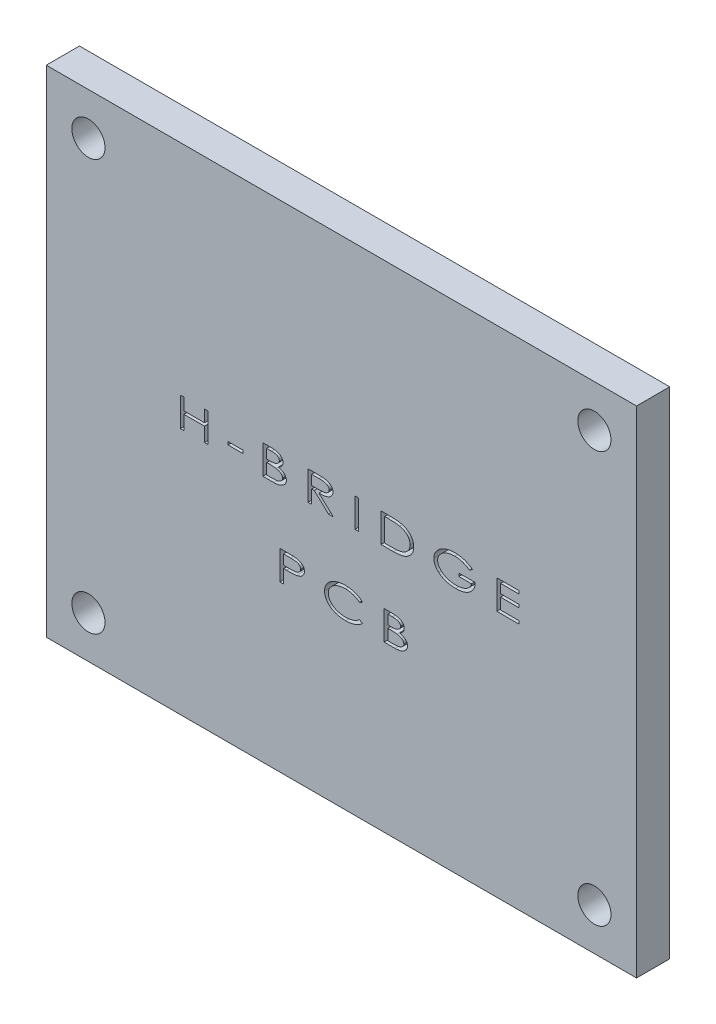
from build123d import *

# Parameters (mm, degrees)
SKETCH1_W           = 71.12
SKETCH1_H           = 59.69
SKETCH1_R           = 2
BOSS_EXTRUDE1_DEPTH = 4
SKETCH2_W           = 1.83974359
SKETCH2_H           = 0.358974359
SKETCH2_W_2         = 0.448717949
SKETCH2_H_2         = 3.5
CUT_EXTRUDE1_DEPTH  = 2


with BuildPart() as part:
    # Sketch1 → Boss-Extrude1 (new body)
    with BuildSketch(Plane.XY):
        Rectangle(SKETCH1_W, SKETCH1_H)
        with Locations((-30.48, 24.765)):
            Circle(SKETCH1_R, mode=Mode.SUBTRACT)
        with Locations((30.48, 24.765)):
            Circle(SKETCH1_R, mode=Mode.SUBTRACT)
        with Locations((30.48, -24.765)):
            Circle(SKETCH1_R, mode=Mode.SUBTRACT)
        with Locations((-30.48, -24.765)):
            Circle(SKETCH1_R, mode=Mode.SUBTRACT)
    extrude(amount=BOSS_EXTRUDE1_DEPTH)

    # Sketch2 → Cut-Extrude1 (cut)
    with BuildSketch(Plane.XY.offset(4)):
        Polygon((-19.416666667, 3.5), (-18.967948718, 3.5), (-18.967948718, 2.064102564), (-16.5, 2.064102564), (-16.5, 3.5), (-16.051282051, 3.5), (-16.051282051, 0), (-16.5, 0), (-16.5, 1.705128205), (-18.967948718, 1.705128205), (-18.967948718, 0), (-19.416666667, 0), align=None)
        with Locations((-12.753205128, 1.346153847)):
            Rectangle(SKETCH2_W, SKETCH2_H)
        with BuildLine():
            Line((-9.455128205, 3.5), (-8.533153045, 3.5))
            add(Edge.make_bspline(
                [(-8.533153045, 3.5), (-8.488041399, 3.499823655), (-8.400593622, 3.499481815), (-8.273430035, 3.494209075), (-8.154368838, 3.487000001), (-8.043325168, 3.475599928), (-7.940396922, 3.46179686), (-7.845331536, 3.445166645), (-7.758375785, 3.425167566), (-7.655029387, 3.393636944), (-7.537589238, 3.346724898), (-7.409410516, 3.277758566), (-7.298608106, 3.192441724), (-7.218657641, 3.111366501), (-7.164194648, 3.041181136), (-7.129110397, 2.986827303), (-7.098696178, 2.931804142), (-7.07450918, 2.87463447), (-7.05599124, 2.816101356), (-7.041358501, 2.756251505), (-7.033885465, 2.694835766), (-7.032665889, 2.653528971), (-7.032051282, 2.63271234)],
                knots=[0, 0, 0, 0, 0.000135324, 0.000262322, 0.000381762, 0.000493105, 0.00059712, 0.000693255, 0.00078254, 0.000864605, 0.001017193, 0.001161224, 0.001299771, 0.001435124, 0.001501598, 0.001565967, 0.001629029, 0.001689975, 0.001751836, 0.001813059, 0.001874543, 0.001937005, 0.001937005, 0.001937005, 0.001937005], degree=3))
            add(Edge.make_bspline(
                [(-7.032051282, 2.63271234), (-7.033801336, 2.593993452), (-7.037259381, 2.517486283), (-7.065054119, 2.405587669), (-7.11041967, 2.299283087), (-7.174112207, 2.199117417), (-7.255788496, 2.10709866), (-7.353442206, 2.022774194), (-7.469103875, 1.948936906), (-7.55435108, 1.908888751), (-7.598557692, 1.888120994)],
                knots=[0, 0, 0, 0, 0.000116044, 0.000229298, 0.000343639, 0.000461511, 0.000583728, 0.000711488, 0.000847429, 0.000993858, 0.000993858, 0.000993858, 0.000993858], degree=3))
            add(Edge.make_bspline(
                [(-7.598557692, 1.888120994), (-7.569061666, 1.880594119), (-7.511692969, 1.865954623), (-7.428851893, 1.841539455), (-7.351819224, 1.815030637), (-7.279017246, 1.789837163), (-7.21232687, 1.761378328), (-7.150027815, 1.733570172), (-7.093206676, 1.704355005), (-7.025702043, 1.663281344), (-6.948905465, 1.609550463), (-6.866194376, 1.538278639), (-6.795490258, 1.459539286), (-6.735294232, 1.375087597), (-6.687437542, 1.285680123), (-6.653271688, 1.191519455), (-6.632366576, 1.093734494), (-6.629596666, 1.02701027), (-6.628205128, 0.993489583)],
                knots=[0, 0, 0, 0, 9.1321e-05, 0.000177616, 0.000258985, 0.000335719, 0.000408636, 0.000476409, 0.00054038, 0.000600141, 0.000713352, 0.00082119, 0.000926929, 0.001030032, 0.001131654, 0.001230131, 0.001329685, 0.001430191, 0.001430191, 0.001430191, 0.001430191], degree=3))
            add(Edge.make_bspline(
                [(-6.628205128, 0.993489583), (-6.629312896, 0.959265668), (-6.631501891, 0.891637791), (-6.652142822, 0.792654516), (-6.684307521, 0.697678316), (-6.730708706, 0.607022938), (-6.790339067, 0.52055519), (-6.862020388, 0.437502288), (-6.947431859, 0.359429113), (-7.044107209, 0.285615537), (-7.152134642, 0.218594814), (-7.269429479, 0.159266074), (-7.396367, 0.110792358), (-7.531669043, 0.069685033), (-7.675943128, 0.038606878), (-7.829152035, 0.016492532), (-7.990902738, 0.001887185), (-8.101930064, 0.000638883), (-8.158754006, 0)],
                knots=[0, 0, 0, 0, 0.000102558, 0.000202659, 0.000301991, 0.000402643, 0.000507072, 0.000616429, 0.000731039, 0.000853599, 0.000980832, 0.001111897, 0.001247306, 0.00138793, 0.001535767, 0.001689556, 0.001852121, 0.002022545, 0.002022545, 0.002022545, 0.002022545], degree=3))
            Line((-8.158754006, 0), (-9.455128205, 0))
            Line((-9.455128205, 0), (-9.455128205, 3.5))
        make_face()
        with BuildLine():
            Line((-9.006410256, 3.141025641), (-9.006410256, 2.019230769))
            Line((-9.006410256, 2.019230769), (-8.730869391, 2.019230769))
            add(Edge.make_bspline(
                [(-8.730869391, 2.019230769), (-8.69043827, 2.019627664), (-8.612371404, 2.020394013), (-8.499197347, 2.022648356), (-8.394514577, 2.028713808), (-8.297882097, 2.035155282), (-8.209720589, 2.04497187), (-8.129819628, 2.057062005), (-8.057966843, 2.069654928), (-7.975191146, 2.0912437), (-7.881777735, 2.122415049), (-7.781559732, 2.171834664), (-7.693219223, 2.230341198), (-7.618240907, 2.298123513), (-7.557164032, 2.37303985), (-7.513254636, 2.45356088), (-7.48523709, 2.538576294), (-7.482266105, 2.596977759), (-7.480769231, 2.626402244)],
                knots=[0, 0, 0, 0, 0.000121302, 0.000234218, 0.000339535, 0.000435845, 0.00052473, 0.000605541, 0.000678286, 0.000743415, 0.000862037, 0.000973036, 0.001077653, 0.001178912, 0.00127516, 0.001366143, 0.001452848, 0.001540891, 0.001540891, 0.001540891, 0.001540891], degree=3))
            add(Edge.make_bspline(
                [(-7.480769231, 2.626402244), (-7.481338977, 2.645864677), (-7.48246102, 2.684193503), (-7.494408609, 2.739692316), (-7.511710492, 2.792544223), (-7.537236579, 2.842004202), (-7.570615094, 2.887808484), (-7.61120844, 2.93012482), (-7.658394963, 2.969491453), (-7.71309168, 3.005620032), (-7.775685219, 3.037576275), (-7.846408359, 3.066036214), (-7.926071023, 3.088290317), (-8.013914704, 3.108464872), (-8.110600888, 3.122197635), (-8.215530749, 3.133928892), (-8.329059106, 3.139833153), (-8.407647214, 3.140618972), (-8.448317308, 3.141025641)],
                knots=[0, 0, 0, 0, 5.8299e-05, 0.000114812, 0.000169576, 0.000224764, 0.000281003, 0.000339027, 0.00040025, 0.000465004, 0.000535245, 0.000610759, 0.000693295, 0.000783107, 0.000880975, 0.000986043, 0.0010998, 0.001221813, 0.001221813, 0.001221813, 0.001221813], degree=3))
            Line((-8.448317308, 3.141025641), (-9.006410256, 3.141025641))
        make_face(mode=Mode.SUBTRACT)
        with BuildLine():
            Line((-9.006410256, 1.66025641), (-9.006410256, 0.358974359))
            Line((-9.006410256, 0.358974359), (-8.404847756, 0.358974359))
            add(Edge.make_bspline(
                [(-8.404847756, 0.358974359), (-8.362078425, 0.359357953), (-8.279335763, 0.360100063), (-8.159636132, 0.362535474), (-8.048787346, 0.367915566), (-7.947163216, 0.376730185), (-7.854214245, 0.385933314), (-7.770267569, 0.39860839), (-7.694891342, 0.413161535), (-7.607533136, 0.43499843), (-7.509358061, 0.469539183), (-7.402801018, 0.521269749), (-7.3081888, 0.583415811), (-7.227191442, 0.655182766), (-7.160951009, 0.733564611), (-7.11291371, 0.817027218), (-7.081883396, 0.903937782), (-7.078567704, 0.963798082), (-7.076923077, 0.993489583)],
                knots=[0, 0, 0, 0, 0.000128313, 0.000248238, 0.000359157, 0.000461167, 0.000554234, 0.00063931, 0.000715761, 0.00078446, 0.000909301, 0.0010272, 0.001139013, 0.001247778, 0.001350833, 0.001445362, 0.0015356, 0.001624411, 0.001624411, 0.001624411, 0.001624411], degree=3))
            add(Edge.make_bspline(
                [(-7.076923077, 0.993489583), (-7.077659306, 1.01198932), (-7.079123434, 1.048779465), (-7.088975002, 1.103097196), (-7.106319827, 1.15538333), (-7.129094607, 1.20616788), (-7.160298225, 1.25439578), (-7.197281808, 1.301223856), (-7.241095924, 1.346179895), (-7.291144554, 1.389013457), (-7.34683226, 1.429141457), (-7.407545478, 1.466811295), (-7.473759477, 1.500057931), (-7.544547024, 1.531077333), (-7.620674635, 1.558454685), (-7.701763653, 1.581976813), (-7.787896942, 1.602476333), (-7.847166602, 1.613321009), (-7.877604167, 1.618890224)],
                knots=[0, 0, 0, 0, 5.5499e-05, 0.000110371, 0.000164914, 0.000220445, 0.000276854, 0.000336749, 0.000399224, 0.000464853, 0.000534133, 0.00060496, 0.000678961, 0.000756202, 0.000836709, 0.00092146, 0.001009381, 0.001102197, 0.001102197, 0.001102197, 0.001102197], degree=3))
            add(Edge.make_bspline(
                [(-7.877604167, 1.618890224), (-7.900016437, 1.622341709), (-7.948450755, 1.629800583), (-8.027079168, 1.637770294), (-8.117077628, 1.644824844), (-8.218560148, 1.649973796), (-8.331416353, 1.655379203), (-8.455559113, 1.657486227), (-8.591102698, 1.659986103), (-8.685294826, 1.660163812), (-8.734375, 1.66025641)],
                knots=[0, 0, 0, 0, 6.802e-05, 0.000146995, 0.000237012, 0.000338829, 0.000451816, 0.000575947, 0.000711279, 0.000858517, 0.000858517, 0.000858517, 0.000858517], degree=3))
            Line((-8.734375, 1.66025641), (-9.006410256, 1.66025641))
        make_face(mode=Mode.SUBTRACT)
        with BuildLine():
            Line((-4.025641026, 3.5), (-3.067908654, 3.5))
            add(Edge.make_bspline(
                [(-3.067908654, 3.5), (-3.003873069, 3.499846464), (-2.88117335, 3.49955227), (-2.705167203, 3.497863617), (-2.545330065, 3.493121233), (-2.401538212, 3.488992081), (-2.274195206, 3.481521981), (-2.16285684, 3.474375001), (-2.067645333, 3.464910648), (-2.009656411, 3.456259654), (-1.983273237, 3.452323718)],
                knots=[0, 0, 0, 0, 0.000192109, 0.000368103, 0.000528014, 0.000671828, 0.000799624, 0.00091067, 0.001006526, 0.001086543, 0.001086543, 0.001086543, 0.001086543], degree=3))
            add(Edge.make_bspline(
                [(-1.983273237, 3.452323718), (-1.948350403, 3.446016522), (-1.879667628, 3.433612154), (-1.780038146, 3.407255004), (-1.685197473, 3.376468726), (-1.59516043, 3.341085056), (-1.510683828, 3.299117541), (-1.430747547, 3.253219852), (-1.355803971, 3.201790331), (-1.287093895, 3.145035008), (-1.223313109, 3.085594585), (-1.169562267, 3.020342373), (-1.122637687, 2.952943451), (-1.084323259, 2.881814355), (-1.055877801, 2.806887279), (-1.03439104, 2.729044074), (-1.021615894, 2.647624197), (-1.020031949, 2.592091546), (-1.019230769, 2.564002404)],
                knots=[0, 0, 0, 0, 0.000106427, 0.000209311, 0.000308863, 0.000405468, 0.000499222, 0.000591578, 0.000681816, 0.000771499, 0.000858777, 0.000942891, 0.001024571, 0.00110487, 0.001184555, 0.001264495, 0.001346799, 0.001431038, 0.001431038, 0.001431038, 0.001431038], degree=3))
            add(Edge.make_bspline(
                [(-1.019230769, 2.564002404), (-1.019690919, 2.540365148), (-1.020601109, 2.493609942), (-1.030237201, 2.424675525), (-1.044738154, 2.358008324), (-1.065307927, 2.293422705), (-1.091847811, 2.231209558), (-1.124685877, 2.171186918), (-1.162233527, 2.112784203), (-1.20670647, 2.057406857), (-1.256669546, 2.005187097), (-1.310635779, 1.954783687), (-1.370525735, 1.908784212), (-1.435260917, 1.865613982), (-1.505563392, 1.826945281), (-1.580108615, 1.789908276), (-1.660135093, 1.757308465), (-1.745486672, 1.727570456), (-1.837775901, 1.701628298), (-1.93758234, 1.678380703), (-2.046088467, 1.660026734), (-2.162482968, 1.643701792), (-2.287158214, 1.631343142), (-2.42019787, 1.622293204), (-2.561417226, 1.616674367), (-2.658448283, 1.615821967), (-2.708233173, 1.615384615)],
                knots=[0, 0, 0, 0, 7.0869e-05, 0.000140181, 0.000208395, 0.000275359, 0.000343208, 0.000410971, 0.000480396, 0.000551241, 0.00062365, 0.000697084, 0.000772535, 0.000849929, 0.000930286, 0.001013066, 0.00109952, 0.001189322, 0.001284087, 0.001386983, 0.001496602, 0.0016141, 0.001739536, 0.001872362, 0.002014099, 0.002163453, 0.002163453, 0.002163453, 0.002163453], degree=3))
            Line((-2.708233173, 1.615384615), (-0.974358974, 0))
            Line((-0.974358974, 0), (-1.543669872, 0))
            Line((-1.543669872, 0), (-3.277544071, 1.615384615))
            Line((-3.277544071, 1.615384615), (-3.576923077, 1.615384615))
            Line((-3.576923077, 1.615384615), (-3.576923077, 0))
            Line((-3.576923077, 0), (-4.025641026, 0))
            Line((-4.025641026, 0), (-4.025641026, 3.5))
        make_face()
        with BuildLine():
            Line((-3.576923077, 3.141025641), (-3.576923077, 1.974358974))
            Line((-3.576923077, 1.974358974), (-2.716646635, 1.969451122))
            add(Edge.make_bspline(
                [(-2.716646635, 1.969451122), (-2.676211126, 1.969434552), (-2.598127372, 1.969402554), (-2.485247007, 1.973406262), (-2.380499969, 1.97794307), (-2.283932675, 1.984879775), (-2.195301774, 1.993908084), (-2.114820101, 2.004943879), (-2.042469676, 2.018044391), (-1.958558809, 2.038249345), (-1.864887366, 2.069306504), (-1.763530494, 2.116181243), (-1.67596091, 2.173985543), (-1.601615238, 2.240628404), (-1.542652297, 2.314695009), (-1.499249389, 2.3939186), (-1.472777791, 2.477970848), (-1.469559341, 2.535775888), (-1.467948718, 2.564703526)],
                knots=[0, 0, 0, 0, 0.000121296, 0.000234231, 0.000338813, 0.000435822, 0.000524632, 0.000606038, 0.000679472, 0.000745112, 0.000864838, 0.000974923, 0.001079152, 0.001178429, 0.001273255, 0.001361721, 0.001448218, 0.001534866, 0.001534866, 0.001534866, 0.001534866], degree=3))
            add(Edge.make_bspline(
                [(-1.467948718, 2.564703526), (-1.469561864, 2.592934747), (-1.47278688, 2.649374857), (-1.499368018, 2.731662988), (-1.543249257, 2.809140843), (-1.603532945, 2.880965136), (-1.676465592, 2.94617385), (-1.761414973, 3.002487793), (-1.857179356, 3.047607995), (-1.945241266, 3.07695664), (-2.024070736, 3.095210486), (-2.093086399, 3.107643545), (-2.17122866, 3.118073547), (-2.25849566, 3.126154967), (-2.35478717, 3.133260414), (-2.460462533, 3.13800775), (-2.575004133, 3.140813302), (-2.654478756, 3.140953222), (-2.695612981, 3.141025641)],
                knots=[0, 0, 0, 0, 8.4554e-05, 0.000169042, 0.000256617, 0.000350248, 0.000449056, 0.000549201, 0.000654885, 0.000765742, 0.000826965, 0.000897514, 0.000976046, 0.001063391, 0.0011604, 0.001265682, 0.0013807, 0.0015041, 0.0015041, 0.0015041, 0.0015041], degree=3))
            Line((-2.695612981, 3.141025641), (-3.576923077, 3.141025641))
        make_face(mode=Mode.SUBTRACT)
        with Locations((1.852564103, 1.75)):
            Rectangle(SKETCH2_W_2, SKETCH2_H_2)
        with BuildLine():
            Line((4.769230769, 0), (4.769230769, 3.5))
            Line((4.769230769, 3.5), (5.740985577, 3.5))
            add(Edge.make_bspline(
                [(5.740985577, 3.5), (5.82559047, 3.499556846), (5.988976861, 3.498701041), (6.224840058, 3.49329804), (6.442958631, 3.483683773), (6.6428254, 3.469712491), (6.82503906, 3.452621883), (6.989008867, 3.43109482), (7.135147401, 3.40592615), (7.225589237, 3.384059125), (7.268028846, 3.373798077)],
                knots=[0, 0, 0, 0, 0.000253815, 0.000490159, 0.000707729, 0.000908739, 0.001091174, 0.00125667, 0.001404792, 0.00153575, 0.00153575, 0.00153575, 0.00153575], degree=3))
            add(Edge.make_bspline(
                [(7.268028846, 3.373798077), (7.323650764, 3.358428176), (7.432734778, 3.328285194), (7.589603002, 3.270981315), (7.737033767, 3.205640317), (7.875989649, 3.133234847), (8.004137, 3.050433379), (8.124525342, 2.961519036), (8.234446261, 2.863076274), (8.335036608, 2.757242699), (8.424428735, 2.644324801), (8.503828648, 2.526490871), (8.56966984, 2.402427242), (8.624138475, 2.273450208), (8.666229983, 2.138894546), (8.696442033, 1.99907483), (8.71405923, 1.853982615), (8.716640607, 1.755656158), (8.717948718, 1.705829327)],
                knots=[0, 0, 0, 0, 0.000173065, 0.00033941, 0.000500437, 0.000656624, 0.000808911, 0.000957689, 0.001105174, 0.001250983, 0.001395191, 0.001536755, 0.00167665, 0.00181585, 0.001956217, 0.00209896, 0.002244451, 0.002393923, 0.002393923, 0.002393923, 0.002393923], degree=3))
            add(Edge.make_bspline(
                [(8.717948718, 1.705829327), (8.716961583, 1.662559049), (8.715014074, 1.577191455), (8.70089318, 1.451211921), (8.676694714, 1.329432547), (8.64434261, 1.211077254), (8.599915847, 1.097425633), (8.548439005, 0.986760526), (8.486356388, 0.880537952), (8.414679633, 0.779250537), (8.335917172, 0.683192567), (8.2511237, 0.592798516), (8.161200295, 0.508542914), (8.064165297, 0.432156117), (7.962755073, 0.360978349), (7.854824649, 0.297005057), (7.741261843, 0.2398555), (7.621472064, 0.187739326), (7.492646551, 0.142652001), (7.352539142, 0.104209634), (7.200238921, 0.072463419), (7.035761135, 0.045957686), (6.859173344, 0.024954578), (6.670390748, 0.010790902), (6.46954928, 0.001267706), (6.331575711, 0.000430946), (6.260516827, 0)],
                knots=[0, 0, 0, 0, 0.0001298, 0.000256082, 0.000379696, 0.000502008, 0.000623623, 0.000745314, 0.00086785, 0.000992146, 0.0011172, 0.001240214, 0.001363741, 0.001486487, 0.001610382, 0.001735193, 0.001862497, 0.001991568, 0.002126832, 0.002271586, 0.00242711, 0.002593322, 0.002771252, 0.002960428, 0.003161155, 0.003374315, 0.003374315, 0.003374315, 0.003374315], degree=3))
            Line((6.260516827, 0), (4.769230769, 0))
        make_face()
        with BuildLine():
            Line((5.217948718, 0.358974359), (5.764823718, 0.358974359))
            add(Edge.make_bspline(
                [(5.764823718, 0.358974359), (5.843351352, 0.359220203), (5.994108698, 0.359692173), (6.211015271, 0.363896695), (6.409232287, 0.370736596), (6.588779924, 0.380259921), (6.749358373, 0.392971345), (6.89116478, 0.407058556), (7.014330452, 0.424697068), (7.089543055, 0.440646553), (7.124298878, 0.448016827)],
                knots=[0, 0, 0, 0, 0.000235581, 0.000452269, 0.00065081, 0.000830565, 0.000991617, 0.001134007, 0.00125805, 0.001364614, 0.001364614, 0.001364614, 0.001364614], degree=3))
            add(Edge.make_bspline(
                [(7.124298878, 0.448016827), (7.167659857, 0.459250295), (7.252950205, 0.481346345), (7.376480427, 0.521632052), (7.49218215, 0.569602837), (7.601147639, 0.62296896), (7.702780592, 0.68306515), (7.796924552, 0.750096987), (7.884647313, 0.822425504), (7.964411351, 0.901531189), (8.035859461, 0.986320247), (8.098651975, 1.075493697), (8.151750631, 1.169332902), (8.194505849, 1.268168418), (8.228350318, 1.371387669), (8.25208843, 1.479184457), (8.266363951, 1.591395565), (8.268263727, 1.667692859), (8.269230769, 1.706530449)],
                knots=[0, 0, 0, 0, 0.000134361, 0.000264287, 0.000389411, 0.000509816, 0.000628015, 0.00074318, 0.0008562, 0.000968741, 0.001079698, 0.001188428, 0.001295482, 0.001402552, 0.001510972, 0.00162086, 0.001733217, 0.001849707, 0.001849707, 0.001849707, 0.001849707], degree=3))
            add(Edge.make_bspline(
                [(8.269230769, 1.706530449), (8.268448596, 1.747488208), (8.266909138, 1.828100476), (8.249955019, 1.946331201), (8.224049923, 2.059878504), (8.188472741, 2.169386991), (8.141069454, 2.273863339), (8.083943853, 2.374187068), (8.016410201, 2.469829048), (7.938345896, 2.56009143), (7.851537607, 2.644731211), (7.756456879, 2.7230537), (7.652701412, 2.793823435), (7.541383069, 2.858535888), (7.42123305, 2.915130861), (7.293780268, 2.965774315), (7.157729291, 3.008566805), (7.063680965, 3.03126862), (7.015625, 3.04286859)],
                knots=[0, 0, 0, 0, 0.000122794, 0.000241682, 0.000357505, 0.00047191, 0.000586453, 0.000701071, 0.000817786, 0.000937104, 0.001058577, 0.001181115, 0.001306162, 0.001434957, 0.001566986, 0.001704212, 0.001846127, 0.001994409, 0.001994409, 0.001994409, 0.001994409], degree=3))
            add(Edge.make_bspline(
                [(7.015625, 3.04286859), (6.975734942, 3.051006147), (6.890268729, 3.068441223), (6.752030967, 3.08694971), (6.596103905, 3.103779657), (6.422166464, 3.117723776), (6.230211653, 3.127809096), (6.020313996, 3.135394023), (5.792426227, 3.14049617), (5.634418027, 3.140844695), (5.552383814, 3.141025641)],
                knots=[0, 0, 0, 0, 0.000122104, 0.000261613, 0.000418169, 0.000592612, 0.000785007, 0.000994784, 0.001222701, 0.001468799, 0.001468799, 0.001468799, 0.001468799], degree=3))
            Line((5.552383814, 3.141025641), (5.217948718, 3.141025641))
            Line((5.217948718, 3.141025641), (5.217948718, 0.358974359))
        make_face(mode=Mode.SUBTRACT)
        with BuildLine():
            Line((15.807692308, 2.902644231), (15.438201122, 2.647435897))
            add(Edge.make_bspline(
                [(15.438201122, 2.647435897), (15.372307745, 2.693412707), (15.240817678, 2.785159316), (15.030817679, 2.902970077), (14.811255352, 3.0026264), (14.584552522, 3.084506932), (14.355208529, 3.149771584), (14.126870444, 3.1957973), (13.901431154, 3.225605673), (13.751859478, 3.22905744), (13.677684295, 3.230769231)],
                knots=[0, 0, 0, 0, 0.000240934, 0.000480783, 0.000721124, 0.000963543, 0.001203251, 0.001435766, 0.001661871, 0.001884314, 0.001884314, 0.001884314, 0.001884314], degree=3))
            add(Edge.make_bspline(
                [(13.677684295, 3.230769231), (13.632090072, 3.230370905), (13.541493358, 3.229579422), (13.406561006, 3.218906279), (13.273373019, 3.203974248), (13.141678069, 3.181936798), (13.011532743, 3.15410732), (12.882884311, 3.119539442), (12.755991596, 3.079027706), (12.631922615, 3.032029985), (12.511747769, 2.980899222), (12.398163735, 2.923881052), (12.291111498, 2.863050848), (12.191464964, 2.797030944), (12.098670414, 2.726587495), (12.011973544, 2.652655217), (11.933438256, 2.572973129), (11.861970237, 2.489799576), (11.798552069, 2.403833455), (11.742391499, 2.316557405), (11.695668024, 2.22748331), (11.656557363, 2.13768355), (11.627129943, 2.046213608), (11.605123623, 1.9539458), (11.592189052, 1.859976263), (11.590560599, 1.797013619), (11.58974359, 1.765424679)],
                knots=[0, 0, 0, 0, 0.000136748, 0.00027172, 0.000405823, 0.000538723, 0.000672113, 0.000804938, 0.000938197, 0.001071545, 0.001202825, 0.001329813, 0.001452606, 0.001572003, 0.00168811, 0.001801953, 0.001913502, 0.00202339, 0.002130664, 0.002233748, 0.002334422, 0.0024321, 0.002527217, 0.002622283, 0.002716383, 0.002811128, 0.002811128, 0.002811128, 0.002811128], degree=3))
            add(Edge.make_bspline(
                [(11.58974359, 1.765424679), (11.590422821, 1.733115092), (11.591782866, 1.668420651), (11.606883835, 1.572321134), (11.628723505, 1.476999581), (11.661867147, 1.383517032), (11.702367156, 1.290687303), (11.752397439, 1.199066789), (11.812505704, 1.109591483), (11.880270554, 1.021183884), (11.956403599, 0.936317022), (12.039633244, 0.855094779), (12.129805163, 0.778888305), (12.227650969, 0.707817213), (12.331493636, 0.640525859), (12.443087446, 0.578931918), (12.560885037, 0.521272196), (12.685256966, 0.469043269), (12.814776057, 0.42239357), (12.947704026, 0.380738679), (13.08402783, 0.346551112), (13.223296958, 0.318683384), (13.365419242, 0.295778234), (13.510819568, 0.281084179), (13.659061462, 0.270385467), (13.75899428, 0.269618404), (13.809495192, 0.269230769)],
                knots=[0, 0, 0, 0, 9.6846e-05, 0.000193918, 0.000291192, 0.000389861, 0.000490949, 0.000594803, 0.000702532, 0.000814019, 0.000928723, 0.001044246, 0.001162655, 0.001282555, 0.001406828, 0.001533628, 0.001664698, 0.001800124, 0.001938076, 0.002077564, 0.002217853, 0.002359479, 0.002503565, 0.002649514, 0.002797776, 0.002949244, 0.002949244, 0.002949244, 0.002949244], degree=3))
            add(Edge.make_bspline(
                [(13.809495192, 0.269230769), (13.870288202, 0.270178016), (13.989468558, 0.272035026), (14.164546832, 0.286468638), (14.332521673, 0.309114976), (14.493371956, 0.342218275), (14.647271174, 0.384258952), (14.794229939, 0.435099334), (14.933483113, 0.496535034), (15.06484799, 0.56616819), (15.18623061, 0.643316664), (15.295661728, 0.726742222), (15.391373105, 0.816293072), (15.475281125, 0.910424118), (15.544880788, 1.011150366), (15.601527817, 1.117457581), (15.645856092, 1.22910387), (15.663988855, 1.30707502), (15.673076923, 1.346153846)],
                knots=[0, 0, 0, 0, 0.000182358, 0.000357499, 0.000526657, 0.000690561, 0.000849765, 0.001004981, 0.001156613, 0.00130591, 0.001450615, 0.001587623, 0.001718086, 0.001843272, 0.001965214, 0.002084405, 0.002204059, 0.002324286, 0.002324286, 0.002324286, 0.002324286], degree=3))
            Line((15.673076923, 1.346153846), (14.147435897, 1.346153846))
            Line((14.147435897, 1.346153846), (14.147435897, 1.705128205))
            Line((14.147435897, 1.705128205), (16.121794872, 1.705128205))
            add(Edge.make_bspline(
                [(16.121794872, 1.705128205), (16.120907172, 1.67122972), (16.119154152, 1.604287361), (16.111665767, 1.504988074), (16.098171278, 1.408365958), (16.080106338, 1.314226041), (16.056666321, 1.223083578), (16.02976373, 1.134282005), (15.996328111, 1.048579627), (15.958667026, 0.965120294), (15.915766222, 0.884358923), (15.868049599, 0.806348756), (15.815078904, 0.731179216), (15.757962171, 0.658214058), (15.694949389, 0.588650116), (15.627526023, 0.521301161), (15.555606658, 0.4559985), (15.451886532, 0.373521367), (15.31278524, 0.278653657), (15.132999482, 0.179049666), (14.939345915, 0.095740793), (14.732049953, 0.027837584), (14.511651638, -0.025270308), (14.27773651, -0.062820084), (14.030561088, -0.085390898), (13.861193031, -0.088269241), (13.774439103, -0.08974359)],
                knots=[0, 0, 0, 0, 0.000101723, 0.000200882, 0.000298549, 0.000394252, 0.000488288, 0.000580765, 0.000672429, 0.000764051, 0.000855321, 0.000946588, 0.001038202, 0.001131058, 0.001224394, 0.001319581, 0.001416878, 0.001515644, 0.00171692, 0.001921217, 0.002131304, 0.002348363, 0.002574872, 0.002810703, 0.003058516, 0.003318746, 0.003318746, 0.003318746, 0.003318746], degree=3))
            add(Edge.make_bspline(
                [(13.774439103, -0.08974359), (13.721143751, -0.089173584), (13.615899887, -0.088047977), (13.460173423, -0.080058323), (13.308574304, -0.067840272), (13.161289743, -0.04933209), (13.018046857, -0.026551291), (12.879176204, 0.00239239), (12.744439129, 0.036012543), (12.61374443, 0.074364935), (12.487521207, 0.118716926), (12.365390689, 0.167808126), (12.247233261, 0.221646452), (12.133746923, 0.281537886), (12.024012082, 0.345654841), (11.9195182, 0.416502784), (11.81820416, 0.491022694), (11.754214381, 0.545104838), (11.722255609, 0.572115385)],
                knots=[0, 0, 0, 0, 0.00015988, 0.00031572, 0.000467688, 0.000616047, 0.000760935, 0.000902703, 0.001041461, 0.001177451, 0.00131116, 0.001442657, 0.001572228, 0.001700495, 0.001827474, 0.001953288, 0.00207907, 0.002204569, 0.002204569, 0.002204569, 0.002204569], degree=3))
            add(Edge.make_bspline(
                [(11.722255609, 0.572115385), (11.676084261, 0.614516507), (11.585728218, 0.697494325), (11.467281582, 0.833199804), (11.366577164, 0.973743277), (11.283746101, 1.119139543), (11.220383103, 1.270460189), (11.1744921, 1.426260357), (11.146150928, 1.587243361), (11.14274392, 1.696367109), (11.141025641, 1.751402244)],
                knots=[0, 0, 0, 0, 0.000187949, 0.000367811, 0.000539213, 0.000705924, 0.000868693, 0.001030204, 0.001192382, 0.001357397, 0.001357397, 0.001357397, 0.001357397], degree=3))
            add(Edge.make_bspline(
                [(11.141025641, 1.751402244), (11.141804717, 1.792599304), (11.143355716, 1.874615239), (11.160912456, 1.996125699), (11.185094535, 2.115898186), (11.222751784, 2.232737044), (11.268277314, 2.348233559), (11.327118006, 2.460290452), (11.39301646, 2.57187354), (11.471538071, 2.678915047), (11.556888707, 2.783605851), (11.652215522, 2.881407596), (11.75408868, 2.974675807), (11.864206757, 3.061284006), (11.981825762, 3.142211414), (12.106942306, 3.217211125), (12.239542049, 3.28679722), (12.379759068, 3.349468664), (12.525860743, 3.406330541), (12.677375308, 3.455291342), (12.833775418, 3.49661474), (12.994647358, 3.531223972), (13.160480003, 3.556708041), (13.330759674, 3.575580966), (13.50572062, 3.58814601), (13.624143484, 3.589207243), (13.683994391, 3.58974359)],
                knots=[0, 0, 0, 0, 0.000123495, 0.000245856, 0.00036769, 0.000489653, 0.000613599, 0.000739653, 0.000868913, 0.001002009, 0.001137473, 0.001273832, 0.001411311, 0.001551579, 0.001693742, 0.001839355, 0.001988945, 0.002142713, 0.002299868, 0.002459064, 0.002620116, 0.002784993, 0.002952479, 0.003123203, 0.003298889, 0.00347841, 0.00347841, 0.00347841, 0.00347841], degree=3))
            add(Edge.make_bspline(
                [(13.683994391, 3.58974359), (13.732615251, 3.589155255), (13.829449151, 3.58798352), (13.973506929, 3.580097015), (14.115447787, 3.567467479), (14.25514423, 3.550183628), (14.392603881, 3.526827249), (14.528016275, 3.498794317), (14.661445329, 3.465995349), (14.792880671, 3.427274586), (14.922853707, 3.382863523), (15.051970427, 3.333371473), (15.179951245, 3.276745952), (15.307397081, 3.214695767), (15.433931808, 3.145470705), (15.559744141, 3.070640687), (15.685076045, 2.990011975), (15.766553979, 2.931956517), (15.807692308, 2.902644231)],
                knots=[0, 0, 0, 0, 0.00014586, 0.000290497, 0.000432685, 0.000573305, 0.000712659, 0.000850851, 0.000988079, 0.001124742, 0.001261765, 0.001400042, 0.00153943, 0.001681474, 0.001825168, 0.001971984, 0.002120564, 0.002272086, 0.002272086, 0.002272086, 0.002272086], degree=3))
        make_face()
        Polygon((18.724358974, 3.5), (21.416666667, 3.5), (21.416666667, 3.141025641), (19.173076923, 3.141025641), (19.173076923, 2.064102564), (21.416666667, 2.064102564), (21.416666667, 1.705128205), (19.173076923, 1.705128205), (19.173076923, 0.358974359), (21.416666667, 0.358974359), (21.416666667, 0), (18.724358974, 0), align=None)
        with BuildLine():
            Line((-7.416666667, -6.5), (-6.472255609, -6.5))
            add(Edge.make_bspline(
                [(-6.472255609, -6.5), (-6.407283514, -6.50005176), (-6.282941449, -6.500150817), (-6.104850777, -6.503156423), (-5.943110512, -6.50720939), (-5.797967652, -6.512775409), (-5.669118873, -6.519329549), (-5.557182475, -6.528642103), (-5.461378029, -6.538263518), (-5.403474118, -6.548103008), (-5.377103365, -6.552584135)],
                knots=[0, 0, 0, 0, 0.000194913, 0.00037302, 0.000534333, 0.000680274, 0.000808771, 0.00092132, 0.001017251, 0.001097476, 0.001097476, 0.001097476, 0.001097476], degree=3))
            add(Edge.make_bspline(
                [(-5.377103365, -6.552584135), (-5.343823287, -6.559183289), (-5.278445395, -6.572147166), (-5.18362961, -6.598300799), (-5.093478678, -6.629210821), (-5.007888556, -6.664837628), (-4.926992529, -6.705521131), (-4.850932523, -6.751385414), (-4.779292019, -6.801781665), (-4.712774664, -6.856951579), (-4.65251728, -6.916343096), (-4.5991986, -6.979514869), (-4.555354769, -7.0472651), (-4.517803362, -7.117960127), (-4.490401146, -7.193173966), (-4.469536473, -7.271698582), (-4.457667702, -7.354072636), (-4.455983855, -7.410253627), (-4.455128205, -7.438802083)],
                knots=[0, 0, 0, 0, 0.000101757, 0.000199899, 0.000294797, 0.000387507, 0.00047781, 0.000566187, 0.000653724, 0.000740351, 0.000825129, 0.000907268, 0.000987775, 0.0010668, 0.001146891, 0.001227328, 0.00131022, 0.00139586, 0.00139586, 0.00139586, 0.00139586], degree=3))
            add(Edge.make_bspline(
                [(-4.455128205, -7.438802083), (-4.455946827, -7.467592129), (-4.45755138, -7.524022531), (-4.469867203, -7.606692423), (-4.489310651, -7.685460413), (-4.516864931, -7.760547436), (-4.552621241, -7.831771477), (-4.597535407, -7.898344481), (-4.648655681, -7.962186417), (-4.708699589, -8.020824565), (-4.775426438, -8.075224142), (-4.847779225, -8.126129707), (-4.926565882, -8.17142951), (-5.011240354, -8.212583838), (-5.102312515, -8.247578443), (-5.198770807, -8.279606926), (-5.301444373, -8.306117043), (-5.372351217, -8.320010352), (-5.408653846, -8.327123397)],
                knots=[0, 0, 0, 0, 8.6341e-05, 0.000169233, 0.000250176, 0.000329365, 0.000408694, 0.000488616, 0.000569864, 0.000653651, 0.000739832, 0.000827942, 0.000918734, 0.00101218, 0.001110089, 0.001211192, 0.001316966, 0.001427932, 0.001427932, 0.001427932, 0.001427932], degree=3))
            add(Edge.make_bspline(
                [(-5.408653846, -8.327123397), (-5.438772352, -8.331783458), (-5.504678596, -8.341980745), (-5.612753246, -8.353454691), (-5.738307531, -8.363123286), (-5.88163043, -8.370489088), (-6.042669033, -8.376702413), (-6.221461439, -8.381663811), (-6.418026746, -8.384402614), (-6.55498714, -8.384542396), (-6.626502404, -8.384615385)],
                knots=[0, 0, 0, 0, 9.142e-05, 0.000200049, 0.000325933, 0.00046917, 0.000630551, 0.000809405, 0.001005739, 0.001220283, 0.001220283, 0.001220283, 0.001220283], degree=3))
            Line((-6.626502404, -8.384615385), (-6.967948718, -8.384615385))
            Line((-6.967948718, -8.384615385), (-6.967948718, -10))
            Line((-6.967948718, -10), (-7.416666667, -10))
            Line((-7.416666667, -10), (-7.416666667, -6.5))
        make_face()
        with BuildLine():
            Line((-6.967948718, -6.858974359), (-6.967948718, -8.025641026))
            Line((-6.967948718, -8.025641026), (-6.139222756, -8.033353365))
            add(Edge.make_bspline(
                [(-6.139222756, -8.033353365), (-6.098787264, -8.03337099), (-6.020703539, -8.033405024), (-5.907589633, -8.02937889), (-5.80284308, -8.024887548), (-5.706495571, -8.018007558), (-5.618878891, -8.008653335), (-5.539415284, -7.998855718), (-5.46865277, -7.985211964), (-5.386422128, -7.966346018), (-5.294818817, -7.935537345), (-5.195702964, -7.888556338), (-5.109647787, -7.83070309), (-5.035993065, -7.764307284), (-4.977970437, -7.689971922), (-4.934207095, -7.611144506), (-4.9088928, -7.526799033), (-4.905530653, -7.46910842), (-4.903846154, -7.440204327)],
                knots=[0, 0, 0, 0, 0.000121296, 0.000234231, 0.000339514, 0.000435823, 0.000523936, 0.000603858, 0.000675913, 0.000740026, 0.00085687, 0.000965057, 0.001068119, 0.001166878, 0.001261269, 0.001349736, 0.001436031, 0.001522678, 0.001522678, 0.001522678, 0.001522678], degree=3))
            add(Edge.make_bspline(
                [(-4.903846154, -7.440204327), (-4.905542042, -7.411996565), (-4.908941788, -7.355448499), (-4.934396415, -7.272574781), (-4.977938863, -7.194572399), (-5.036209293, -7.121193159), (-5.108107413, -7.055291846), (-5.191473097, -6.998462869), (-5.285300631, -6.952078775), (-5.372253433, -6.923041854), (-5.449707155, -6.904941037), (-5.517273034, -6.892244069), (-5.593575333, -6.881981175), (-5.678501475, -6.873893649), (-5.771982838, -6.866695518), (-5.874157846, -6.86202532), (-5.985192773, -6.859171865), (-6.062097411, -6.859041899), (-6.102063301, -6.858974359)],
                knots=[0, 0, 0, 0, 8.4554e-05, 0.000169506, 0.000257356, 0.000351196, 0.000449439, 0.000548813, 0.000652912, 0.00076244, 0.00082298, 0.000891461, 0.000968603, 0.001053855, 0.001147368, 0.001249849, 0.001360662, 0.001480556, 0.001480556, 0.001480556, 0.001480556], degree=3))
            Line((-6.102063301, -6.858974359), (-6.967948718, -6.858974359))
        make_face(mode=Mode.SUBTRACT)
        with BuildLine():
            Line((2.544871795, -7.142227564), (2.169070513, -7.352564103))
            add(Edge.make_bspline(
                [(2.169070513, -7.352564103), (2.142905265, -7.329141966), (2.09057303, -7.282296136), (2.007460623, -7.216980942), (1.920468543, -7.156155828), (1.829988075, -7.098967168), (1.7349475, -7.047191123), (1.636136366, -6.999605129), (1.533648608, -6.956106923), (1.42764419, -6.916873553), (1.318456991, -6.881801381), (1.206148081, -6.851601776), (1.091167034, -6.826717656), (0.973628018, -6.805232213), (0.853301332, -6.789575679), (0.730569974, -6.777452171), (0.605188877, -6.770258542), (0.52074238, -6.769576346), (0.477964744, -6.769230769)],
                knots=[0, 0, 0, 0, 0.000105332, 0.00021067, 0.000316874, 0.00042367, 0.000531609, 0.000641363, 0.000752574, 0.000865489, 0.000980345, 0.001096505, 0.001214227, 0.001333188, 0.001454855, 0.001578129, 0.001703125, 0.001831448, 0.001831448, 0.001831448, 0.001831448], degree=3))
            add(Edge.make_bspline(
                [(0.477964744, -6.769230769), (0.431202461, -6.769625533), (0.338505572, -6.770408074), (0.200765764, -6.781059284), (0.065707129, -6.79595772), (-0.066741357, -6.817829424), (-0.196456072, -6.846203614), (-0.324113855, -6.879111403), (-0.44844653, -6.920622158), (-0.569962643, -6.966128642), (-0.686551929, -7.01807881), (-0.797433219, -7.07389311), (-0.90141377, -7.134248367), (-0.998477143, -7.198726545), (-1.088455983, -7.267807757), (-1.172432186, -7.340509885), (-1.248569923, -7.418771356), (-1.318939748, -7.499789528), (-1.381592584, -7.584357752), (-1.434644298, -7.672577351), (-1.481104417, -7.762628264), (-1.517716602, -7.856111589), (-1.547877655, -7.951501462), (-1.567761096, -8.050007514), (-1.581002973, -8.150780222), (-1.582553008, -8.219107807), (-1.583333333, -8.253505609)],
                knots=[0, 0, 0, 0, 0.000140252, 0.000278022, 0.000414215, 0.000547806, 0.000680511, 0.000812478, 0.00094307, 0.001073546, 0.001201614, 0.001325781, 0.001445794, 0.001562079, 0.001675105, 0.001785911, 0.001894985, 0.002002364, 0.002107677, 0.002210245, 0.002310897, 0.002411277, 0.002511073, 0.002610628, 0.002712375, 0.002815526, 0.002815526, 0.002815526, 0.002815526], degree=3))
            add(Edge.make_bspline(
                [(-1.583333333, -8.253505609), (-1.581723075, -8.305295604), (-1.578550739, -8.407325975), (-1.549105147, -8.556634228), (-1.503234791, -8.699570284), (-1.436463686, -8.835044416), (-1.35371618, -8.965407878), (-1.249789451, -9.087459951), (-1.128625734, -9.203561685), (-0.990118367, -9.311224973), (-0.837925393, -9.409611393), (-0.67451399, -9.496010377), (-0.50084626, -9.568161597), (-0.318066616, -9.627960487), (-0.125523715, -9.674081204), (0.076747735, -9.706559892), (0.288445412, -9.727703704), (0.43304083, -9.72973454), (0.506710737, -9.730769231)],
                knots=[0, 0, 0, 0, 0.000155216, 0.000305787, 0.000454782, 0.000604358, 0.000757613, 0.000916865, 0.001083975, 0.001260275, 0.001442303, 0.00162703, 0.001814014, 0.0020058, 0.002203402, 0.002407304, 0.002620017, 0.002840961, 0.002840961, 0.002840961, 0.002840961], degree=3))
            add(Edge.make_bspline(
                [(0.506710737, -9.730769231), (0.547621166, -9.730438198), (0.628802686, -9.729781307), (0.749225501, -9.722308977), (0.867393804, -9.711440443), (0.98266726, -9.695165479), (1.095705561, -9.674889811), (1.205844979, -9.649669324), (1.313795889, -9.620290492), (1.418883644, -9.585589421), (1.521948955, -9.547649804), (1.621851229, -9.503293244), (1.719962807, -9.456440883), (1.814691122, -9.403103001), (1.907552949, -9.346734375), (1.997127362, -9.284473182), (2.085240866, -9.21905013), (2.14105541, -9.171368721), (2.169070513, -9.147435897)],
                knots=[0, 0, 0, 0, 0.000122714, 0.000243511, 0.000361832, 0.000478636, 0.000592643, 0.00070626, 0.0008175, 0.000928137, 0.00103818, 0.001146815, 0.001255938, 0.001364215, 0.001472799, 0.001581705, 0.001691361, 0.001801867, 0.001801867, 0.001801867, 0.001801867], degree=3))
            Line((2.169070513, -9.147435897), (2.544871795, -9.355669071))
            add(Edge.make_bspline(
                [(2.544871795, -9.355669071), (2.515007661, -9.38425665), (2.455070571, -9.441631705), (2.359673171, -9.522382885), (2.258320898, -9.597499738), (2.151355296, -9.667566464), (2.039522379, -9.733559571), (1.921879212, -9.793893925), (1.799015392, -9.849317719), (1.671010905, -9.899577224), (1.538458462, -9.94465002), (1.401438061, -9.983020068), (1.260800706, -10.015757132), (1.116340868, -10.043500955), (0.96819996, -10.064295086), (0.816130899, -10.078776242), (0.660380597, -10.088379453), (0.555102696, -10.089285088), (0.501802885, -10.08974359)],
                knots=[0, 0, 0, 0, 0.000124005, 0.000248878, 0.00037466, 0.000502226, 0.000632333, 0.000764034, 0.000898653, 0.001036531, 0.001176435, 0.001318488, 0.001463214, 0.001609522, 0.001759641, 0.001911797, 0.002067713, 0.002227593, 0.002227593, 0.002227593, 0.002227593], degree=3))
            add(Edge.make_bspline(
                [(0.501802885, -10.08974359), (0.451309735, -10.089479848), (0.351430041, -10.088958144), (0.203916633, -10.080592766), (0.060285758, -10.069114608), (-0.079026082, -10.051975186), (-0.214841774, -10.031459301), (-0.346161607, -10.004524025), (-0.47371947, -9.973779919), (-0.597049643, -9.938102491), (-0.716380755, -9.8974222), (-0.83157298, -9.851937205), (-0.942428201, -9.801040845), (-1.049792496, -9.746892951), (-1.152550603, -9.686797195), (-1.251465155, -9.622151231), (-1.3470544, -9.55334085), (-1.406958702, -9.502826844), (-1.436798878, -9.477664263)],
                knots=[0, 0, 0, 0, 0.000151457, 0.000299595, 0.000443119, 0.000583653, 0.000720595, 0.000855071, 0.00098567, 0.001114144, 0.001240081, 0.001363767, 0.001485504, 0.001605911, 0.001724359, 0.0018424, 0.001960341, 0.002077403, 0.002077403, 0.002077403, 0.002077403], degree=3))
            add(Edge.make_bspline(
                [(-1.436798878, -9.477664263), (-1.484267658, -9.434449447), (-1.577230332, -9.349817718), (-1.697861021, -9.208973146), (-1.801404133, -9.06260744), (-1.886006311, -8.909121039), (-1.952017191, -8.74876152), (-1.997889141, -8.581558286), (-2.027234329, -8.40785163), (-2.03043067, -8.289615609), (-2.032051282, -8.229667468)],
                knots=[0, 0, 0, 0, 0.000192422, 0.000376838, 0.000555011, 0.000729482, 0.000901476, 0.001073965, 0.001248706, 0.001428424, 0.001428424, 0.001428424, 0.001428424], degree=3))
            add(Edge.make_bspline(
                [(-2.032051282, -8.229667468), (-2.031522443, -8.197864509), (-2.030474553, -8.134847289), (-2.021800266, -8.041414787), (-2.007797914, -7.949856651), (-1.988142217, -7.860167405), (-1.963115918, -7.772157902), (-1.931126716, -7.686738961), (-1.894665404, -7.602800482), (-1.852539546, -7.520830199), (-1.804908774, -7.440480466), (-1.750368245, -7.36292165), (-1.69167501, -7.286242033), (-1.62697586, -7.211630526), (-1.556002225, -7.139825887), (-1.479938879, -7.06916707), (-1.398034665, -7.000907366), (-1.281756228, -6.911705953), (-1.126835533, -6.80874189), (-0.92857587, -6.702124158), (-0.718887711, -6.612177965), (-0.498385873, -6.537664183), (-0.265965898, -6.480139277), (-0.022346274, -6.440207061), (0.232507878, -6.414948458), (0.406155881, -6.411842034), (0.494791667, -6.41025641)],
                knots=[0, 0, 0, 0, 9.5394e-05, 0.000189022, 0.00028124, 0.000373106, 0.000464308, 0.000555478, 0.00064653, 0.000738718, 0.000831786, 0.000926502, 0.001022985, 0.001121392, 0.001222533, 0.001325729, 0.001432735, 0.001542256, 0.001765297, 0.001989906, 0.002216655, 0.002449013, 0.002687419, 0.002934083, 0.003189073, 0.003454931, 0.003454931, 0.003454931, 0.003454931], degree=3))
            add(Edge.make_bspline(
                [(0.494791667, -6.41025641), (0.548790483, -6.410740158), (0.655698707, -6.411697893), (0.813833928, -6.420973222), (0.96794258, -6.436488618), (1.118076034, -6.45762061), (1.264535892, -6.483563648), (1.406553726, -6.517869861), (1.544643799, -6.556891457), (1.678550353, -6.601635288), (1.807386409, -6.652158518), (1.930893619, -6.707241067), (2.048045464, -6.767988361), (2.160086174, -6.832002467), (2.264996445, -6.902468483), (2.364603094, -6.97691261), (2.457853206, -7.056783946), (2.515970905, -7.113849758), (2.544871795, -7.142227564)],
                knots=[0, 0, 0, 0, 0.000161983, 0.000320699, 0.000475017, 0.000626525, 0.000775461, 0.000921032, 0.001064625, 0.001205857, 0.001344388, 0.001479647, 0.001611347, 0.001740142, 0.001866539, 0.001990217, 0.002113033, 0.002234522, 0.002234522, 0.002234522, 0.002234522], degree=3))
        make_face()
        with BuildLine():
            Line((5.147435897, -6.5), (6.069411058, -6.5))
            add(Edge.make_bspline(
                [(6.069411058, -6.5), (6.114522704, -6.500176345), (6.20197048, -6.500518185), (6.329134067, -6.505790925), (6.448195264, -6.512999999), (6.559238935, -6.524400072), (6.66216718, -6.53820314), (6.757232567, -6.554833355), (6.844188317, -6.574832434), (6.947534715, -6.606363056), (7.064974865, -6.653275102), (7.193153587, -6.722241434), (7.303955997, -6.807558276), (7.383906461, -6.888633499), (7.438369454, -6.958818864), (7.473453706, -7.013172697), (7.503867924, -7.068195858), (7.528054922, -7.12536553), (7.546572862, -7.183898644), (7.561205601, -7.243748495), (7.568678637, -7.305164234), (7.569898213, -7.346471029), (7.570512821, -7.36728766)],
                knots=[0, 0, 0, 0, 0.000135324, 0.000262322, 0.000381762, 0.000493105, 0.00059712, 0.000693255, 0.00078254, 0.000864605, 0.001017193, 0.001161224, 0.001299771, 0.001435124, 0.001501598, 0.001565967, 0.001629029, 0.001689975, 0.001751836, 0.001813059, 0.001874543, 0.001937005, 0.001937005, 0.001937005, 0.001937005], degree=3))
            add(Edge.make_bspline(
                [(7.570512821, -7.36728766), (7.568762767, -7.406006548), (7.565304722, -7.482513717), (7.537509983, -7.594412331), (7.492144433, -7.700716913), (7.428451896, -7.800882583), (7.346775606, -7.89290134), (7.249121896, -7.977225806), (7.133460227, -8.051063094), (7.048213022, -8.091111249), (7.00400641, -8.111879006)],
                knots=[0, 0, 0, 0, 0.000116044, 0.000229298, 0.000343639, 0.000461511, 0.000583728, 0.000711488, 0.000847429, 0.000993858, 0.000993858, 0.000993858, 0.000993858], degree=3))
            add(Edge.make_bspline(
                [(7.00400641, -8.111879006), (7.033502437, -8.119405881), (7.090871133, -8.134045377), (7.173712209, -8.158460545), (7.250744879, -8.184969363), (7.323546857, -8.210162837), (7.390237232, -8.238621672), (7.452536288, -8.266429828), (7.509357426, -8.295644995), (7.576862059, -8.336718656), (7.653658637, -8.390449537), (7.736369727, -8.461721361), (7.807073845, -8.540460714), (7.867269871, -8.624912403), (7.91512656, -8.714319877), (7.949292414, -8.808480545), (7.970197527, -8.906265506), (7.972967437, -8.97298973), (7.974358974, -9.006510417)],
                knots=[0, 0, 0, 0, 9.1321e-05, 0.000177616, 0.000258985, 0.000335719, 0.000408636, 0.000476409, 0.00054038, 0.000600141, 0.000713352, 0.00082119, 0.000926929, 0.001030032, 0.001131654, 0.001230131, 0.001329685, 0.001430191, 0.001430191, 0.001430191, 0.001430191], degree=3))
            add(Edge.make_bspline(
                [(7.974358974, -9.006510417), (7.973251207, -9.040734332), (7.971062212, -9.108362209), (7.95042128, -9.207345484), (7.918256582, -9.302321684), (7.871855397, -9.392977062), (7.812225036, -9.47944481), (7.740543715, -9.562497712), (7.655132243, -9.640570887), (7.558456894, -9.714384463), (7.45042946, -9.781405186), (7.333134623, -9.840733926), (7.206197103, -9.889207642), (7.07089506, -9.930314967), (6.926620974, -9.961393122), (6.773412068, -9.983507468), (6.611661365, -9.998112815), (6.500634038, -9.999361117), (6.443810096, -10)],
                knots=[0, 0, 0, 0, 0.000102558, 0.000202659, 0.000301991, 0.000402643, 0.000507072, 0.000616429, 0.000731039, 0.000853599, 0.000980832, 0.001111897, 0.001247306, 0.00138793, 0.001535767, 0.001689556, 0.001852121, 0.002022545, 0.002022545, 0.002022545, 0.002022545], degree=3))
            Line((6.443810096, -10), (5.147435897, -10))
            Line((5.147435897, -10), (5.147435897, -6.5))
        make_face()
        with BuildLine():
            Line((5.596153846, -6.858974359), (5.596153846, -7.980769231))
            Line((5.596153846, -7.980769231), (5.871694712, -7.980769231))
            add(Edge.make_bspline(
                [(5.871694712, -7.980769231), (5.912125832, -7.980372336), (5.990192699, -7.979605987), (6.103366756, -7.977351644), (6.208049525, -7.971286192), (6.304682005, -7.964844718), (6.392843514, -7.95502813), (6.472744475, -7.942937995), (6.54459726, -7.930345072), (6.627372957, -7.9087563), (6.720786367, -7.877584951), (6.82100437, -7.828165336), (6.90934488, -7.769658802), (6.984323196, -7.701876487), (7.04540007, -7.62696015), (7.089309466, -7.54643912), (7.117327013, -7.461423706), (7.120297997, -7.403022241), (7.121794872, -7.373597756)],
                knots=[0, 0, 0, 0, 0.000121302, 0.000234218, 0.000339535, 0.000435845, 0.00052473, 0.000605541, 0.000678286, 0.000743415, 0.000862037, 0.000973036, 0.001077653, 0.001178912, 0.00127516, 0.001366143, 0.001452848, 0.001540891, 0.001540891, 0.001540891, 0.001540891], degree=3))
            add(Edge.make_bspline(
                [(7.121794872, -7.373597756), (7.121225126, -7.354135323), (7.120103083, -7.315806497), (7.108155494, -7.260307684), (7.090853611, -7.207455777), (7.065327524, -7.157995798), (7.031949008, -7.112191516), (6.991355662, -7.06987518), (6.944169139, -7.030508547), (6.889472423, -6.994379968), (6.826878884, -6.962423725), (6.756155744, -6.933963786), (6.676493079, -6.911709683), (6.588649398, -6.891535128), (6.491963214, -6.877802365), (6.387033353, -6.866071108), (6.273504997, -6.860166847), (6.194916889, -6.859381028), (6.154246795, -6.858974359)],
                knots=[0, 0, 0, 0, 5.8299e-05, 0.000114812, 0.000169576, 0.000224764, 0.000281003, 0.000339027, 0.00040025, 0.000465004, 0.000535245, 0.000610759, 0.000693295, 0.000783107, 0.000880975, 0.000986043, 0.0010998, 0.001221813, 0.001221813, 0.001221813, 0.001221813], degree=3))
            Line((6.154246795, -6.858974359), (5.596153846, -6.858974359))
        make_face(mode=Mode.SUBTRACT)
        with BuildLine():
            Line((5.596153846, -8.33974359), (5.596153846, -9.641025641))
            Line((5.596153846, -9.641025641), (6.197716346, -9.641025641))
            add(Edge.make_bspline(
                [(6.197716346, -9.641025641), (6.240485678, -9.640642047), (6.32322834, -9.639899937), (6.44292797, -9.637464526), (6.553776756, -9.632084434), (6.655400886, -9.623269815), (6.748349858, -9.614066686), (6.832296533, -9.60139161), (6.907672761, -9.586838465), (6.995030967, -9.56500157), (7.093206041, -9.530460817), (7.199763084, -9.478730251), (7.294375303, -9.416584189), (7.375372661, -9.344817234), (7.441613094, -9.266435389), (7.489650392, -9.182972782), (7.520680706, -9.096062218), (7.523996398, -9.036201918), (7.525641026, -9.006510417)],
                knots=[0, 0, 0, 0, 0.000128313, 0.000248238, 0.000359157, 0.000461167, 0.000554234, 0.00063931, 0.000715761, 0.00078446, 0.000909301, 0.0010272, 0.001139013, 0.001247778, 0.001350833, 0.001445362, 0.0015356, 0.001624411, 0.001624411, 0.001624411, 0.001624411], degree=3))
            add(Edge.make_bspline(
                [(7.525641026, -9.006510417), (7.524904796, -8.98801068), (7.523440668, -8.951220535), (7.513589101, -8.896902804), (7.496244276, -8.84461667), (7.473469496, -8.79383212), (7.442265878, -8.74560422), (7.405282295, -8.698776144), (7.361468178, -8.653820105), (7.311419548, -8.610986543), (7.255731842, -8.570858543), (7.195018625, -8.533188705), (7.128804625, -8.499942069), (7.058017079, -8.468922667), (6.981889468, -8.441545315), (6.90080045, -8.418023187), (6.814667161, -8.397523667), (6.755397501, -8.386678991), (6.724959936, -8.381109776)],
                knots=[0, 0, 0, 0, 5.5499e-05, 0.000110371, 0.000164914, 0.000220445, 0.000276854, 0.000336749, 0.000399224, 0.000464853, 0.000534133, 0.00060496, 0.000678961, 0.000756202, 0.000836709, 0.00092146, 0.001009381, 0.001102197, 0.001102197, 0.001102197, 0.001102197], degree=3))
            add(Edge.make_bspline(
                [(6.724959936, -8.381109776), (6.702547666, -8.377658291), (6.654113348, -8.370199417), (6.575484935, -8.362229706), (6.485486475, -8.355175156), (6.384003955, -8.350026204), (6.27114775, -8.344620797), (6.14700499, -8.342513773), (6.011461405, -8.340013897), (5.917269276, -8.339836188), (5.868189103, -8.33974359)],
                knots=[0, 0, 0, 0, 6.802e-05, 0.000146995, 0.000237012, 0.000338829, 0.000451816, 0.000575947, 0.000711279, 0.000858517, 0.000858517, 0.000858517, 0.000858517], degree=3))
            Line((5.868189103, -8.33974359), (5.596153846, -8.33974359))
        make_face(mode=Mode.SUBTRACT)
    extrude(amount=-CUT_EXTRUDE1_DEPTH, mode=Mode.SUBTRACT)


solid = part.part
